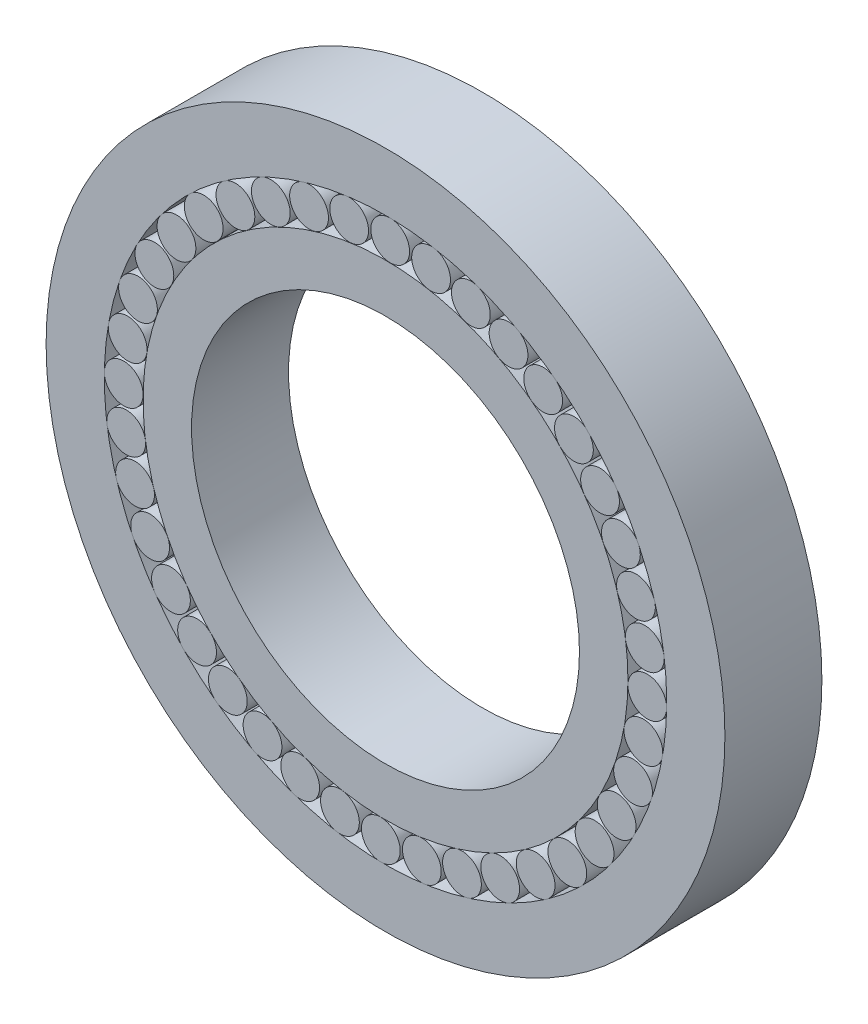
from build123d import *

# Parameters (mm, degrees)
SKETCH2_R              = 25
SKETCH2_R_2            = 20
BOSS_EXTRUDE1_DEPTH    = 10
SKETCH2_R_3            = 2
BOSS_EXTRUDE1_2_DEPTH  = 10
BOSS_EXTRUDE1_3_DEPTH  = 10
BOSS_EXTRUDE1_4_DEPTH  = 10
BOSS_EXTRUDE1_5_DEPTH  = 10
BOSS_EXTRUDE1_6_DEPTH  = 10
BOSS_EXTRUDE1_7_DEPTH  = 10
BOSS_EXTRUDE1_8_DEPTH  = 10
BOSS_EXTRUDE1_9_DEPTH  = 10
BOSS_EXTRUDE1_10_DEPTH = 10
BOSS_EXTRUDE1_11_DEPTH = 10
BOSS_EXTRUDE1_12_DEPTH = 10
BOSS_EXTRUDE1_13_DEPTH = 10
BOSS_EXTRUDE1_14_DEPTH = 10
BOSS_EXTRUDE1_15_DEPTH = 10
BOSS_EXTRUDE1_16_DEPTH = 10
BOSS_EXTRUDE1_17_DEPTH = 10
BOSS_EXTRUDE1_18_DEPTH = 10
BOSS_EXTRUDE1_19_DEPTH = 10
BOSS_EXTRUDE1_20_DEPTH = 10
BOSS_EXTRUDE1_21_DEPTH = 10
BOSS_EXTRUDE1_22_DEPTH = 10
BOSS_EXTRUDE1_23_DEPTH = 10
BOSS_EXTRUDE1_24_DEPTH = 10
BOSS_EXTRUDE1_25_DEPTH = 10
BOSS_EXTRUDE1_26_DEPTH = 10
BOSS_EXTRUDE1_27_DEPTH = 10
BOSS_EXTRUDE1_28_DEPTH = 10
BOSS_EXTRUDE1_29_DEPTH = 10
BOSS_EXTRUDE1_30_DEPTH = 10
BOSS_EXTRUDE1_31_DEPTH = 10
BOSS_EXTRUDE1_32_DEPTH = 10
BOSS_EXTRUDE1_33_DEPTH = 10
BOSS_EXTRUDE1_34_DEPTH = 10
SKETCH2_R_4            = 35
SKETCH2_R_5            = 29
BOSS_EXTRUDE1_35_DEPTH = 10
BOSS_EXTRUDE1_36_DEPTH = 10
BOSS_EXTRUDE1_37_DEPTH = 10
BOSS_EXTRUDE1_38_DEPTH = 10
BOSS_EXTRUDE1_39_DEPTH = 10
BOSS_EXTRUDE1_40_DEPTH = 10
BOSS_EXTRUDE1_41_DEPTH = 10
BOSS_EXTRUDE1_42_DEPTH = 10


with BuildPart() as part:
    # Sketch2 → Boss-Extrude1 (new body)
    with BuildSketch(Plane.XY):
        Circle(SKETCH2_R)
        Circle(SKETCH2_R_2, mode=Mode.SUBTRACT)
    extrude(amount=BOSS_EXTRUDE1_DEPTH)


with BuildPart() as body_2:
    # Sketch2 → Boss-Extrude1 2 (new body)
    with BuildSketch(Plane.XY):
        with Locations((16.257459459, 21.556785751)):
            Circle(SKETCH2_R_3)
    extrude(amount=BOSS_EXTRUDE1_2_DEPTH)


with BuildPart() as body_3:
    # Sketch2 → Boss-Extrude1 3 (new body)
    with BuildSketch(Plane.XY):
        with Locations((19.429527403, 18.748158974)):
            Circle(SKETCH2_R_3)
    extrude(amount=BOSS_EXTRUDE1_3_DEPTH)


with BuildPart() as body_4:
    # Sketch2 → Boss-Extrude1 4 (new body)
    with BuildSketch(Plane.XY):
        with Locations((22.123175898, 15.477890301)):
            Circle(SKETCH2_R_3)
    extrude(amount=BOSS_EXTRUDE1_4_DEPTH)


with BuildPart() as body_5:
    # Sketch2 → Boss-Extrude1 5 (new body)
    with BuildSketch(Plane.XY):
        with Locations((24.272078381, 11.8265046)):
            Circle(SKETCH2_R_3)
    extrude(amount=BOSS_EXTRUDE1_5_DEPTH)


with BuildPart() as body_6:
    # Sketch2 → Boss-Extrude1 6 (new body)
    with BuildSketch(Plane.XY):
        with Locations((25.823321739, 7.883911107)):
            Circle(SKETCH2_R_3)
    extrude(amount=BOSS_EXTRUDE1_6_DEPTH)


with BuildPart() as body_7:
    # Sketch2 → Boss-Extrude1 7 (new body)
    with BuildSketch(Plane.XY):
        with Locations((26.738709214, 3.747189557)):
            Circle(SKETCH2_R_3)
    extrude(amount=BOSS_EXTRUDE1_7_DEPTH)


with BuildPart() as body_8:
    # Sketch2 → Boss-Extrude1 8 (new body)
    with BuildSketch(Plane.XY):
        with Locations((26.995700927, -0.481800237)):
            Circle(SKETCH2_R_3)
    extrude(amount=BOSS_EXTRUDE1_8_DEPTH)


with BuildPart() as body_9:
    # Sketch2 → Boss-Extrude1 9 (new body)
    with BuildSketch(Plane.XY):
        with Locations((26.587968889, -4.698926509)):
            Circle(SKETCH2_R_3)
    extrude(amount=BOSS_EXTRUDE1_9_DEPTH)


with BuildPart() as body_10:
    # Sketch2 → Boss-Extrude1 10 (new body)
    with BuildSketch(Plane.XY):
        with Locations((25.525552817, -8.800349616)):
            Circle(SKETCH2_R_3)
    extrude(amount=BOSS_EXTRUDE1_10_DEPTH)


with BuildPart() as body_11:
    # Sketch2 → Boss-Extrude1 11 (new body)
    with BuildSketch(Plane.XY):
        with Locations((23.834612921, -12.685078909)):
            Circle(SKETCH2_R_3)
    extrude(amount=BOSS_EXTRUDE1_11_DEPTH)


with BuildPart() as body_12:
    # Sketch2 → Boss-Extrude1 12 (new body)
    with BuildSketch(Plane.XY):
        with Locations((21.556785751, -16.257459459)):
            Circle(SKETCH2_R_3)
    extrude(amount=BOSS_EXTRUDE1_12_DEPTH)


with BuildPart() as body_13:
    # Sketch2 → Boss-Extrude1 13 (new body)
    with BuildSketch(Plane.XY):
        with Locations((18.748158974, -19.429527403)):
            Circle(SKETCH2_R_3)
    extrude(amount=BOSS_EXTRUDE1_13_DEPTH)


with BuildPart() as body_14:
    # Sketch2 → Boss-Extrude1 14 (new body)
    with BuildSketch(Plane.XY):
        with Locations((7.883911107, -25.823321739)):
            Circle(SKETCH2_R_3)
    extrude(amount=BOSS_EXTRUDE1_14_DEPTH)


with BuildPart() as body_15:
    # Sketch2 → Boss-Extrude1 15 (new body)
    with BuildSketch(Plane.XY):
        with Locations((3.747189557, -26.738709214)):
            Circle(SKETCH2_R_3)
    extrude(amount=BOSS_EXTRUDE1_15_DEPTH)


with BuildPart() as body_16:
    # Sketch2 → Boss-Extrude1 16 (new body)
    with BuildSketch(Plane.XY):
        with Locations((-0.481800237, -26.995700927)):
            Circle(SKETCH2_R_3)
    extrude(amount=BOSS_EXTRUDE1_16_DEPTH)


with BuildPart() as body_17:
    # Sketch2 → Boss-Extrude1 17 (new body)
    with BuildSketch(Plane.XY):
        with Locations((-4.698926509, -26.587968889)):
            Circle(SKETCH2_R_3)
    extrude(amount=BOSS_EXTRUDE1_17_DEPTH)


with BuildPart() as body_18:
    # Sketch2 → Boss-Extrude1 18 (new body)
    with BuildSketch(Plane.XY):
        with Locations((-8.800349616, -25.525552817)):
            Circle(SKETCH2_R_3)
    extrude(amount=BOSS_EXTRUDE1_18_DEPTH)


with BuildPart() as body_19:
    # Sketch2 → Boss-Extrude1 19 (new body)
    with BuildSketch(Plane.XY):
        with Locations((-12.685078909, -23.834612921)):
            Circle(SKETCH2_R_3)
    extrude(amount=BOSS_EXTRUDE1_19_DEPTH)


with BuildPart() as body_20:
    # Sketch2 → Boss-Extrude1 20 (new body)
    with BuildSketch(Plane.XY):
        with Locations((-16.257459459, -21.556785751)):
            Circle(SKETCH2_R_3)
    extrude(amount=BOSS_EXTRUDE1_20_DEPTH)


with BuildPart() as body_21:
    # Sketch2 → Boss-Extrude1 21 (new body)
    with BuildSketch(Plane.XY):
        with Locations((-19.429527403, -18.748158974)):
            Circle(SKETCH2_R_3)
    extrude(amount=BOSS_EXTRUDE1_21_DEPTH)


with BuildPart() as body_22:
    # Sketch2 → Boss-Extrude1 22 (new body)
    with BuildSketch(Plane.XY):
        with Locations((-22.123175898, -15.477890301)):
            Circle(SKETCH2_R_3)
    extrude(amount=BOSS_EXTRUDE1_22_DEPTH)


with BuildPart() as body_23:
    # Sketch2 → Boss-Extrude1 23 (new body)
    with BuildSketch(Plane.XY):
        with Locations((-24.272078381, -11.8265046)):
            Circle(SKETCH2_R_3)
    extrude(amount=BOSS_EXTRUDE1_23_DEPTH)


with BuildPart() as body_24:
    # Sketch2 → Boss-Extrude1 24 (new body)
    with BuildSketch(Plane.XY):
        with Locations((-25.823321739, -7.883911107)):
            Circle(SKETCH2_R_3)
    extrude(amount=BOSS_EXTRUDE1_24_DEPTH)


with BuildPart() as body_25:
    # Sketch2 → Boss-Extrude1 25 (new body)
    with BuildSketch(Plane.XY):
        with Locations((-26.738709214, -3.747189557)):
            Circle(SKETCH2_R_3)
    extrude(amount=BOSS_EXTRUDE1_25_DEPTH)


with BuildPart() as body_26:
    # Sketch2 → Boss-Extrude1 26 (new body)
    with BuildSketch(Plane.XY):
        with Locations((-26.995700927, 0.481800237)):
            Circle(SKETCH2_R_3)
    extrude(amount=BOSS_EXTRUDE1_26_DEPTH)


with BuildPart() as body_27:
    # Sketch2 → Boss-Extrude1 27 (new body)
    with BuildSketch(Plane.XY):
        with Locations((-15.477890301, 22.123175898)):
            Circle(SKETCH2_R_3)
    extrude(amount=BOSS_EXTRUDE1_27_DEPTH)


with BuildPart() as body_28:
    # Sketch2 → Boss-Extrude1 28 (new body)
    with BuildSketch(Plane.XY):
        with Locations((-11.8265046, 24.272078381)):
            Circle(SKETCH2_R_3)
    extrude(amount=BOSS_EXTRUDE1_28_DEPTH)


with BuildPart() as body_29:
    # Sketch2 → Boss-Extrude1 29 (new body)
    with BuildSketch(Plane.XY):
        with Locations((-7.883911107, 25.823321739)):
            Circle(SKETCH2_R_3)
    extrude(amount=BOSS_EXTRUDE1_29_DEPTH)


with BuildPart() as body_30:
    # Sketch2 → Boss-Extrude1 30 (new body)
    with BuildSketch(Plane.XY):
        with Locations((-3.747189557, 26.738709214)):
            Circle(SKETCH2_R_3)
    extrude(amount=BOSS_EXTRUDE1_30_DEPTH)


with BuildPart() as body_31:
    # Sketch2 → Boss-Extrude1 31 (new body)
    with BuildSketch(Plane.XY):
        with Locations((0.481800237, 26.995700927)):
            Circle(SKETCH2_R_3)
    extrude(amount=BOSS_EXTRUDE1_31_DEPTH)


with BuildPart() as body_32:
    # Sketch2 → Boss-Extrude1 32 (new body)
    with BuildSketch(Plane.XY):
        with Locations((4.698926509, 26.587968889)):
            Circle(SKETCH2_R_3)
    extrude(amount=BOSS_EXTRUDE1_32_DEPTH)


with BuildPart() as body_33:
    # Sketch2 → Boss-Extrude1 33 (new body)
    with BuildSketch(Plane.XY):
        with Locations((8.800349616, 25.525552817)):
            Circle(SKETCH2_R_3)
    extrude(amount=BOSS_EXTRUDE1_33_DEPTH)


with BuildPart() as body_34:
    # Sketch2 → Boss-Extrude1 34 (new body)
    with BuildSketch(Plane.XY):
        with Locations((12.685078909, 23.834612921)):
            Circle(SKETCH2_R_3)
    extrude(amount=BOSS_EXTRUDE1_34_DEPTH)


with BuildPart() as body_35:
    # Sketch2 → Boss-Extrude1 35 (new body)
    with BuildSketch(Plane.XY):
        Circle(SKETCH2_R_4)
        Circle(SKETCH2_R_5, mode=Mode.SUBTRACT)
    extrude(amount=BOSS_EXTRUDE1_35_DEPTH)


with BuildPart() as body_36:
    # Sketch2 → Boss-Extrude1 36 (new body)
    with BuildSketch(Plane.XY):
        with Locations((15.477890301, -22.123175898)):
            Circle(SKETCH2_R_3)
    extrude(amount=BOSS_EXTRUDE1_36_DEPTH)


with BuildPart() as body_37:
    # Sketch2 → Boss-Extrude1 37 (new body)
    with BuildSketch(Plane.XY):
        with Locations((11.826504601, -24.272078381)):
            Circle(SKETCH2_R_3)
    extrude(amount=BOSS_EXTRUDE1_37_DEPTH)


with BuildPart() as body_38:
    # Sketch2 → Boss-Extrude1 38 (new body)
    with BuildSketch(Plane.XY):
        with Locations((-26.587968889, 4.698926509)):
            Circle(SKETCH2_R_3)
    extrude(amount=BOSS_EXTRUDE1_38_DEPTH)


with BuildPart() as body_39:
    # Sketch2 → Boss-Extrude1 39 (new body)
    with BuildSketch(Plane.XY):
        with Locations((-25.525552817, 8.800349616)):
            Circle(SKETCH2_R_3)
    extrude(amount=BOSS_EXTRUDE1_39_DEPTH)


with BuildPart() as body_40:
    # Sketch2 → Boss-Extrude1 40 (new body)
    with BuildSketch(Plane.XY):
        with Locations((-23.834612921, 12.685078909)):
            Circle(SKETCH2_R_3)
    extrude(amount=BOSS_EXTRUDE1_40_DEPTH)


with BuildPart() as body_41:
    # Sketch2 → Boss-Extrude1 41 (new body)
    with BuildSketch(Plane.XY):
        with Locations((-21.556785751, 16.257459459)):
            Circle(SKETCH2_R_3)
    extrude(amount=BOSS_EXTRUDE1_41_DEPTH)


with BuildPart() as body_42:
    # Sketch2 → Boss-Extrude1 42 (new body)
    with BuildSketch(Plane.XY):
        with Locations((-18.748158974, 19.429527403)):
            Circle(SKETCH2_R_3)
    extrude(amount=BOSS_EXTRUDE1_42_DEPTH)


solid = Compound([part.part, body_2.part, body_3.part, body_4.part, body_5.part, body_6.part, body_7.part, body_8.part, body_9.part, body_10.part, body_11.part, body_12.part, body_13.part, body_14.part, body_15.part, body_16.part, body_17.part, body_18.part, body_19.part, body_20.part, body_21.part, body_22.part, body_23.part, body_24.part, body_25.part, body_26.part, body_27.part, body_28.part, body_29.part, body_30.part, body_31.part, body_32.part, body_33.part, body_34.part, body_35.part, body_36.part, body_37.part, body_38.part, body_39.part, body_40.part, body_41.part, body_42.part])
